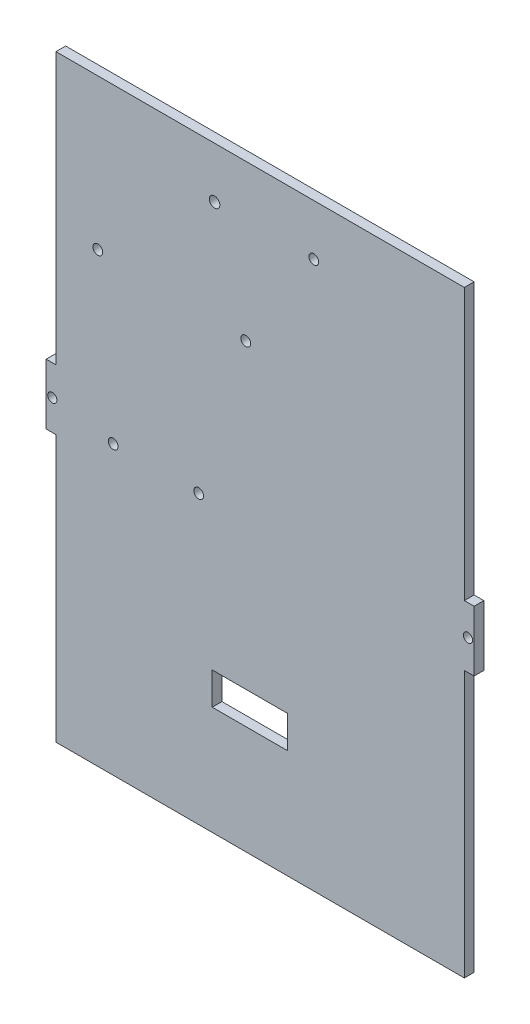
from build123d import *

# Parameters (mm, degrees)
SKETCH1_W           = 139.7
SKETCH1_H           = 200.02
BOSS_EXTRUDE1_DEPTH = 3.18
SKETCH2_R           = 1.5
SKETCH2_W           = 3.18
SKETCH2_H           = 90.135
CUT_EXTRUDE1_DEPTH  = 4.18
SKETCH5_W           = 88.895716174
SKETCH5_H           = 168.56277979
BOSS_EXTRUDE2_DEPTH = 3.18
SKETCH6_W           = 20
SKETCH6_H           = 200.02
BOSS_EXTRUDE3_DEPTH = 3.18
SKETCH7_W           = 56.795
SKETCH7_H           = 3.18
CUT_EXTRUDE4_DEPTH  = 4.18
SKETCH8_W           = 133.34
SKETCH8_H           = 1.59
CUT_EXTRUDE5_DEPTH  = 4.18
SKETCH9_R           = 1.6
CUT_EXTRUDE6_DEPTH  = 4.18
SKETCH10_W          = 24.565797096
SKETCH10_H          = 10.537213664
CUT_EXTRUDE7_DEPTH  = 3.18
SKETCH11_R          = 1.59
SKETCH11_R_2        = 1.71788268
CUT_EXTRUDE8_DEPTH  = 35
SKETCH12_W          = 3.18
SKETCH12_H          = 3.18
CUT_EXTRUDE9_DEPTH  = 80.725


with BuildPart() as part:
    # Sketch1 → Boss-Extrude1 (new body)
    with BuildSketch(Plane.XY):
        Rectangle(SKETCH1_W, SKETCH1_H)
    extrude(amount=BOSS_EXTRUDE1_DEPTH)

    # Sketch2 → Cut-Extrude1 (cut, through all)
    with BuildSketch(Plane.XY.offset(3.18)):
        with Locations((-67.85, 0)):
            Circle(SKETCH2_R)
        with Locations((67.85, 0)):
            Circle(SKETCH2_R)
        Polygon((-10, 100.01), (10, 100.01), (10, 96.83), (1.5, 96.83), (1.5, 92.83), (3.5, 92.83), (3.5, 89.83), (1.5, 89.83), (1.5, 86.83), (-1.5, 86.83), (-1.5, 89.83), (-3.5, 89.83), (-3.5, 92.83), (-1.5, 92.83), (-1.5, 96.83), (-10, 96.83), align=None)
        Polygon((-10, -100.01), (-10, -96.83), (-1.5, -96.83), (-1.5, -92.83), (-3.5, -92.83), (-3.5, -89.83), (-1.5, -89.83), (-1.5, -86.83), (1.5, -86.83), (1.5, -89.83), (3.5, -89.83), (3.5, -92.83), (1.5, -92.83), (1.5, -96.83), (10, -96.83), (10, -100.01), align=None)
        with Locations((-68.26, 54.9425)):
            Rectangle(SKETCH2_W, SKETCH2_H)
        with Locations((-68.26, -54.9425)):
            Rectangle(SKETCH2_W, SKETCH2_H)
        with Locations((68.26, -54.9425)):
            Rectangle(SKETCH2_W, SKETCH2_H)
        with Locations((68.26, 54.9425)):
            Rectangle(SKETCH2_W, SKETCH2_H)
    extrude(amount=-CUT_EXTRUDE1_DEPTH, mode=Mode.SUBTRACT)

    # Sketch5 → Boss-Extrude2 (add)
    with BuildSketch(Plane.XY.offset(3.18)):
        Rectangle(SKETCH5_W, SKETCH5_H)
    extrude(amount=-BOSS_EXTRUDE2_DEPTH)

    # Sketch6 → Boss-Extrude3 (add)
    with BuildSketch(Plane.XY.offset(3.18)):
        Rectangle(SKETCH6_W, SKETCH6_H)
    extrude(amount=-BOSS_EXTRUDE3_DEPTH)

    # Sketch7 → Cut-Extrude4 (cut, through all)
    with BuildSketch(Plane.XY.offset(3.18)):
        with Locations((-38.2725, -98.42)):
            Rectangle(SKETCH7_W, SKETCH7_H)
        with Locations((38.2725, -98.42)):
            Rectangle(SKETCH7_W, SKETCH7_H)
    extrude(amount=-CUT_EXTRUDE4_DEPTH, mode=Mode.SUBTRACT)

    # Sketch8 → Cut-Extrude5 (cut, through all)
    with BuildSketch(Plane.XY.offset(3.18)):
        with Locations((0, 99.215)):
            Rectangle(SKETCH8_W, SKETCH8_H)
    extrude(amount=-CUT_EXTRUDE5_DEPTH, mode=Mode.SUBTRACT)

    # Sketch9 → Cut-Extrude6 (cut, through all)
    with BuildSketch(Plane.XY.offset(3.18)):
        with Locations((-52.981261278, 49.292856132)):
            Circle(SKETCH9_R)
        with Locations((-4.68387739, 47.615742656)):
            Circle(SKETCH9_R)
        with Locations((-20.064964891, -3.1597647)):
            Circle(SKETCH9_R)
        with Locations((-47.964929331, -3.115219713)):
            Circle(SKETCH9_R)
    extrude(amount=-CUT_EXTRUDE6_DEPTH, mode=Mode.SUBTRACT)

    # Sketch10 → Cut-Extrude7 (cut)
    with BuildSketch(Plane.XY.offset(3.18)):
        with Locations((-3.359789788, -56.149532718)):
            Rectangle(SKETCH10_W, SKETCH10_H)
    extrude(amount=-CUT_EXTRUDE7_DEPTH, mode=Mode.SUBTRACT)

    # Sketch11 → Cut-Extrude8 (cut)
    with BuildSketch(Plane.XY.offset(3.18)):
        with Locations((17.523878239, 81.797398404)):
            Circle(SKETCH11_R)
        with Locations((-14.883091948, 81.797398404)):
            Circle(SKETCH11_R_2)
    extrude(amount=-CUT_EXTRUDE8_DEPTH, mode=Mode.SUBTRACT)

    # Sketch12 → Cut-Extrude9 (cut, through all)
    with BuildSketch(Plane.ZY.offset(9.875)):
        with Locations((1.59, -98.42)):
            Rectangle(SKETCH12_W, SKETCH12_H)
    extrude(amount=-CUT_EXTRUDE9_DEPTH, mode=Mode.SUBTRACT)


solid = part.part
